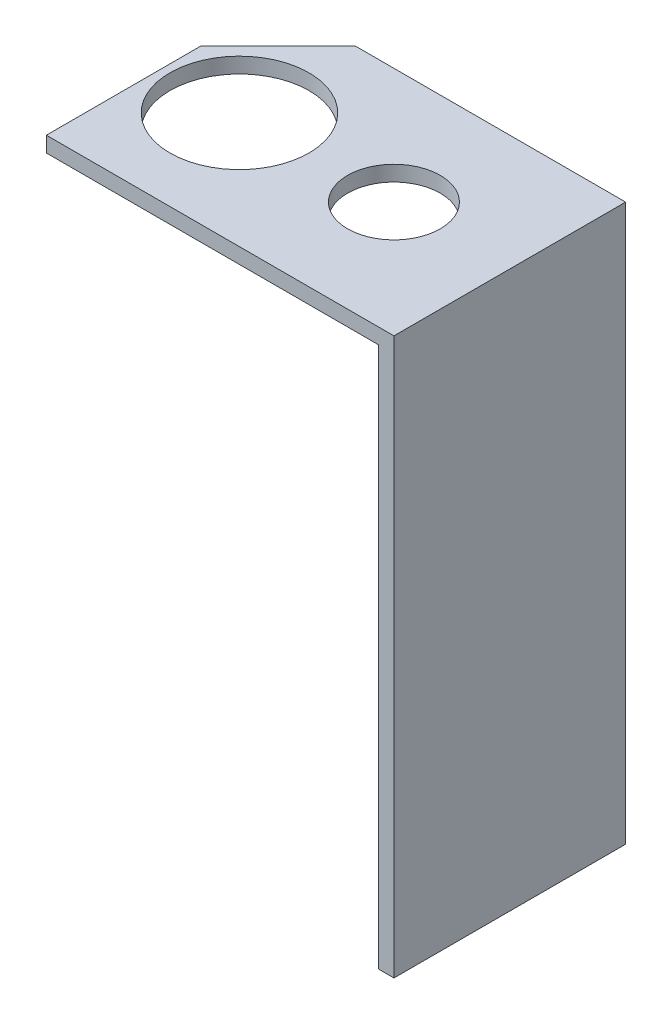
from build123d import *

# Parameters (mm, degrees)
SKETCH1_W           = 45
SKETCH1_H           = 30
BOSS_EXTRUDE1_DEPTH = 2
SKETCH2_R           = 9
SKETCH2_R_2         = 6
CUT_EXTRUDE1_DEPTH  = 20
SKETCH3_W           = 2
SKETCH3_H           = 30
BOSS_EXTRUDE2_DEPTH = 70
CHAMFER1_SIZE       = 10


with BuildPart() as part:
    # Sketch1 → Boss-Extrude1 (new body)
    with BuildSketch(Plane(origin=(0, 0, 0), x_dir=(1, 0, 0), z_dir=(0, 1, 0))):
        with Locations((22.5, 15)):
            Rectangle(SKETCH1_W, SKETCH1_H)
    extrude(amount=BOSS_EXTRUDE1_DEPTH)

    # Sketch2 → Cut-Extrude1 (cut)
    with BuildSketch(Plane(origin=(0, 2, 0), x_dir=(1, 0, 0), z_dir=(0, 1, 0))):
        with Locations((10, 15)):
            Circle(SKETCH2_R)
        with Locations((30, 15)):
            Circle(SKETCH2_R_2)
    extrude(amount=-CUT_EXTRUDE1_DEPTH, mode=Mode.SUBTRACT)

    # Sketch3 → Boss-Extrude2 (add)
    with BuildSketch(Plane.XZ):
        with Locations((44, -15)):
            Rectangle(SKETCH3_W, SKETCH3_H)
    extrude(amount=BOSS_EXTRUDE2_DEPTH)

    # Chamfer1
    chamfer1_edges = [part.edges().sort_by_distance(p)[0] for p in [
        (0, 1, -30),
    ]]
    chamfer(chamfer1_edges, length=CHAMFER1_SIZE)


solid = part.part
